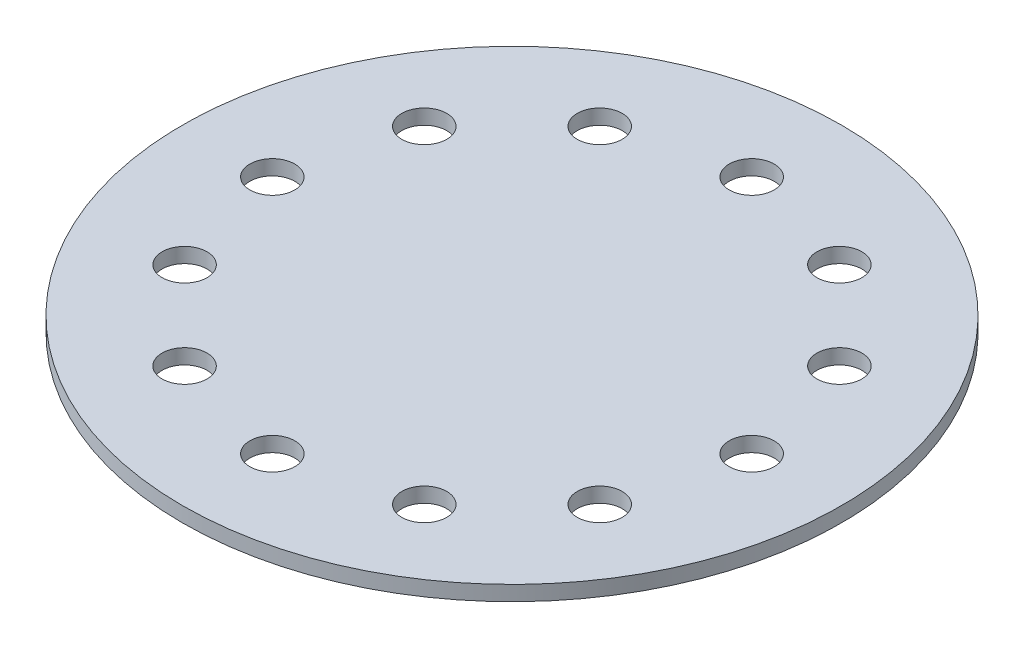
from build123d import *

# Parameters (mm, degrees)
SKETCH1_R           = 22
SKETCH1_R_2         = 1.5
BOSS_EXTRUDE1_DEPTH = 1


with BuildPart() as part:
    # Sketch1 → Boss-Extrude1 (new body)
    with BuildSketch(Plane(origin=(0, 0, 0), x_dir=(1, 0, 0), z_dir=(0, 1, 0))):
        Circle(SKETCH1_R)
        with Locations((0, 16)):
            Circle(SKETCH1_R_2, mode=Mode.SUBTRACT)
        with Locations((8, 13.856406461)):
            Circle(SKETCH1_R_2, mode=Mode.SUBTRACT)
        with Locations((13.856406461, 8)):
            Circle(SKETCH1_R_2, mode=Mode.SUBTRACT)
        with Locations((16, 0)):
            Circle(SKETCH1_R_2, mode=Mode.SUBTRACT)
        with Locations((13.856406461, -8)):
            Circle(SKETCH1_R_2, mode=Mode.SUBTRACT)
        with Locations((8, -13.856406461)):
            Circle(SKETCH1_R_2, mode=Mode.SUBTRACT)
        with Locations((0, -16)):
            Circle(SKETCH1_R_2, mode=Mode.SUBTRACT)
        with Locations((-8, -13.856406461)):
            Circle(SKETCH1_R_2, mode=Mode.SUBTRACT)
        with Locations((-13.856406461, -8)):
            Circle(SKETCH1_R_2, mode=Mode.SUBTRACT)
        with Locations((-16, 0)):
            Circle(SKETCH1_R_2, mode=Mode.SUBTRACT)
        with Locations((-13.856406461, 8)):
            Circle(SKETCH1_R_2, mode=Mode.SUBTRACT)
        with Locations((-8, 13.856406461)):
            Circle(SKETCH1_R_2, mode=Mode.SUBTRACT)
    extrude(amount=BOSS_EXTRUDE1_DEPTH)


solid = part.part
